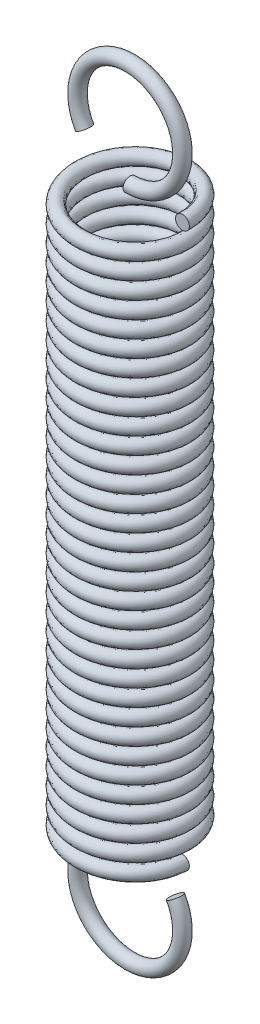
from build123d import *

# Parameters (mm, degrees)
SWEEP1_PITCH       = 0.848484848
SWEEP1_HEIGHT      = 28
SWEEP1_RADIUS      = 2.65
SWEEP1_START_ANGLE = 90
SKETCH3_R          = 0.35
SKETCH4_R          = 0.35
REVOLVE1_ANGLE     = 300
SKETCH7_R          = 0.35
REVOLVE2_ANGLE     = 300


with BuildPart() as part:
    # Sweep1: sweep along a helix
    with BuildLine() as sweep1_path:
        add(Helix(SWEEP1_PITCH, SWEEP1_HEIGHT, SWEEP1_RADIUS, center=(0, 0, 0), direction=(0, 1, 0), lefthand=True, mode=Mode.PRIVATE).rotate(Axis((0, 0, 0), (0, 1, 0)), SWEEP1_START_ANGLE))
    # Sketch3 → Sweep1 (sweep)
    with BuildSketch(Plane.XY):
        with Locations((2.65, 0)):
            Circle(SKETCH3_R)
    sweep(path=sweep1_path.line, is_frenet=True)


with BuildPart() as body_2:
    # Sketch4 → Revolve1 (revolve)
    with BuildSketch(Plane(origin=(0, 0, 0), x_dir=(0, 0, -1), z_dir=(1, 0, 0))):
        with Locations((0, -0.35)):
            Circle(SKETCH4_R)
    revolve(axis=Axis((0, -3, 0), (0, 0, 1)), revolution_arc=REVOLVE1_ANGLE)


with BuildPart() as body_3:
    # Sketch7 → Revolve2 (revolve)
    with BuildSketch(Plane(origin=(0, 0, 0), x_dir=(0, 0, -1), z_dir=(1, 0, 0))):
        with Locations((0, 28.35)):
            Circle(SKETCH7_R)
    revolve(axis=Axis((0, 31, 0), (0, 0, 1)), revolution_arc=REVOLVE2_ANGLE)


solid = Compound([part.part, body_2.part, body_3.part])
